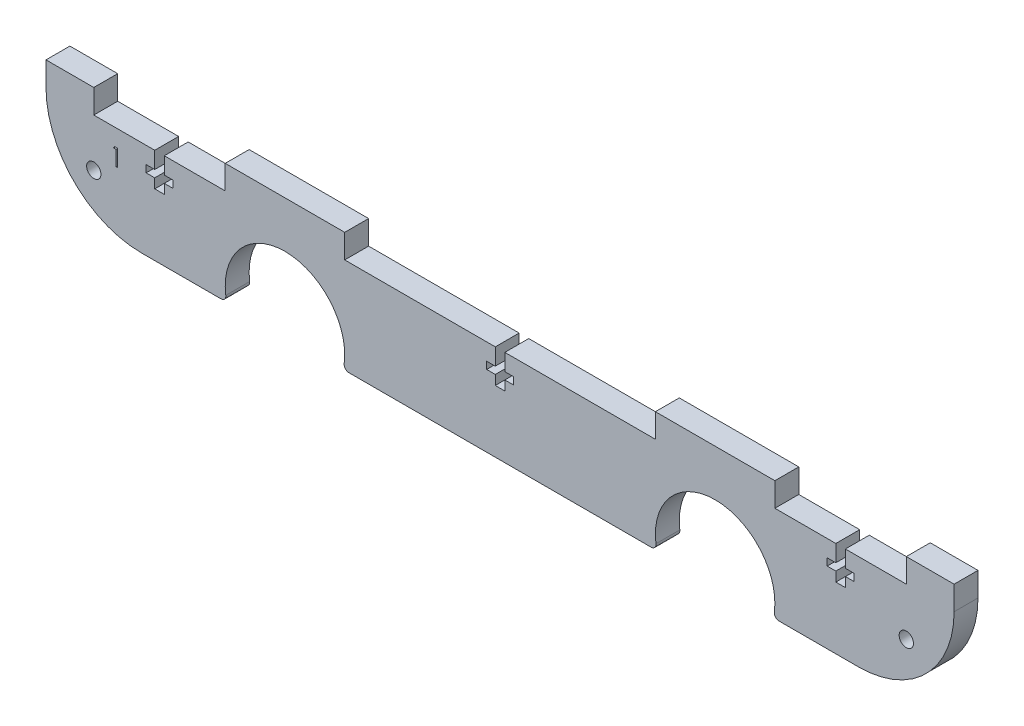
from build123d import *

# Parameters (mm, degrees)
RESSALTO_EXTRUS_O1_DEPTH = 5
ESBO_O2_R                = 12.5
CORTE_EXTRUS_O1_DEPTH    = 10
FILETE2_R                = 1
ESBO_O3_W                = 27.5
ESBO_O3_H                = 5
ESBO_O3_W_2              = 65
CORTE_EXTRUS_O3_DEPTH    = 6
CORTE_EXTRUS_O4_DEPTH    = 6
ESBO_O6_R                = 1.5
CORTE_EXTRUS_O5_DEPTH    = 6


with BuildPart() as part:
    # Esboço1 → Ressalto-extrusão1 (new body)
    with BuildSketch(Plane.XY):
        with BuildLine():
            Line((20, 0), (170, 0))
            ThreePointArc((170, 0), (184.142135624, 5.857864376), (190, 20))
            Line((190, 20), (190, 25))
            Line((190, 25), (0, 25))
            Line((0, 25), (0, 20))
            ThreePointArc((0, 20), (5.857864376, 5.857864376), (20, 0))
        make_face()
    extrude(amount=RESSALTO_EXTRUS_O1_DEPTH)

    # Esboço2 → Corte-extrusão1 (cut)
    with BuildSketch(Plane.XY.offset(5)):
        with Locations((140, 2.8)):
            Circle(ESBO_O2_R)
        with Locations((50, 2.8)):
            Circle(ESBO_O2_R)
    extrude(amount=-CORTE_EXTRUS_O1_DEPTH, mode=Mode.SUBTRACT)

    # Filete2
    filete2_edges = [part.edges().sort_by_distance(p)[0] for p in [
        (127.817635697, 0, 2.5),
        (152.182364303, 0, 2.5),
        (37.817635697, 0, 2.5),
        (62.182364303, 0, 2.5),
    ]]
    fillet(filete2_edges, radius=FILETE2_R)

    # Esboço3 → Corte-extrusão3 (cut, through all)
    with BuildSketch(Plane.XY.offset(5)):
        with Locations((23.75, 22.5)):
            Rectangle(ESBO_O3_W, ESBO_O3_H)
        with Locations((95, 22.5)):
            Rectangle(ESBO_O3_W_2, ESBO_O3_H)
        with Locations((166.25, 22.5)):
            Rectangle(ESBO_O3_W, ESBO_O3_H)
    extrude(amount=-CORTE_EXTRUS_O3_DEPTH, mode=Mode.SUBTRACT)

    # Esboço5 → Corte-extrusão4 (cut, through all)
    with BuildSketch(Plane.XY.offset(5)):
        Polygon((22.75, 13), (22.75, 15), (20.95, 15), (20.95, 16.5), (22.75, 16.5), (22.75, 20), (24.75, 20), (24.75, 16.5), (26.55, 16.5), (26.55, 15), (24.75, 15), (24.75, 13), align=None)
        Polygon((94, 13), (94, 15), (92.2, 15), (92.2, 16.5), (94, 16.5), (94, 20), (96, 20), (96, 16.5), (97.8, 16.5), (97.8, 15), (96, 15), (96, 13), align=None)
        Polygon((165.2510001, 13), (165.2510001, 15), (163.4510001, 15), (163.4510001, 16.5), (165.2510001, 16.5), (165.2510001, 20), (167.2510001, 20), (167.2510001, 16.5), (169.0510001, 16.5), (169.0510001, 15), (167.2510001, 15), (167.2510001, 13), align=None)
    extrude(amount=-CORTE_EXTRUS_O4_DEPTH, mode=Mode.SUBTRACT)

    # Esboço6 → Corte-extrusão5 (cut, through all)
    with BuildSketch(Plane.XY.offset(5)):
        with Locations((180, 10)):
            Circle(ESBO_O6_R)
        with Locations((10, 10)):
            Circle(ESBO_O6_R)
        Polygon((14.350226907, 16.471731735), (14.997362324, 16.471731735), (14.997362324, 12.971731735), (14.68325976, 12.971731735), (14.68325976, 16.112757376), (14.144798222, 16.112757376), align=None)
    extrude(amount=-CORTE_EXTRUS_O5_DEPTH, mode=Mode.SUBTRACT)


solid = part.part
